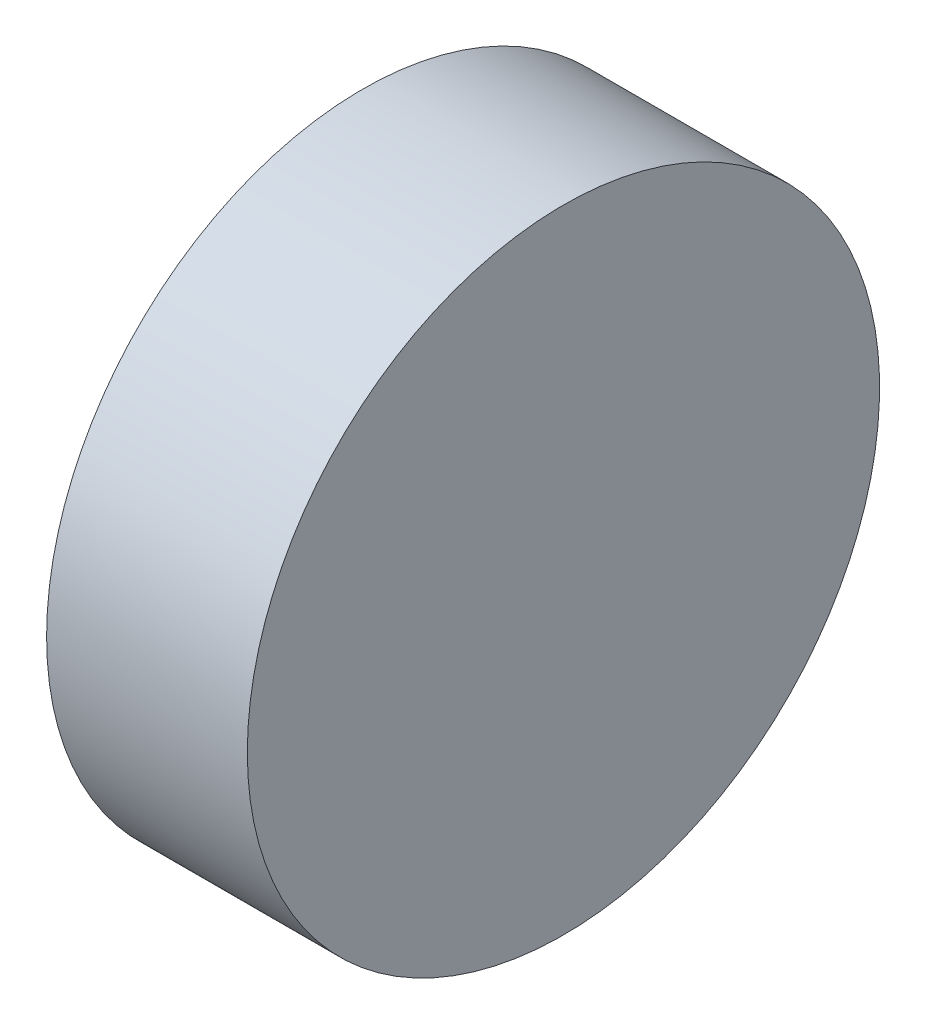
from build123d import *

# Parameters (mm, degrees)
SKETCH_1_W = 2
SKETCH_1_H = 3.15


with BuildPart() as part:
    # 草图1 → 旋转1 (revolve)
    with BuildSketch(Plane.XY, mode=Mode.PRIVATE) as revolve_1_sk:
        with Locations((52.887964479, 17.03363587)):
            Rectangle(SKETCH_1_W, SKETCH_1_H)
    revolve(revolve_1_sk.sketch.rotate(Axis((50.800160399, 15.45863587, 0), (1, 0, 0)), 90), axis=Axis((50.800160399, 15.45863587, 0), (1, 0, 0)))  # turned: the seam where the file's is


solid = part.part
